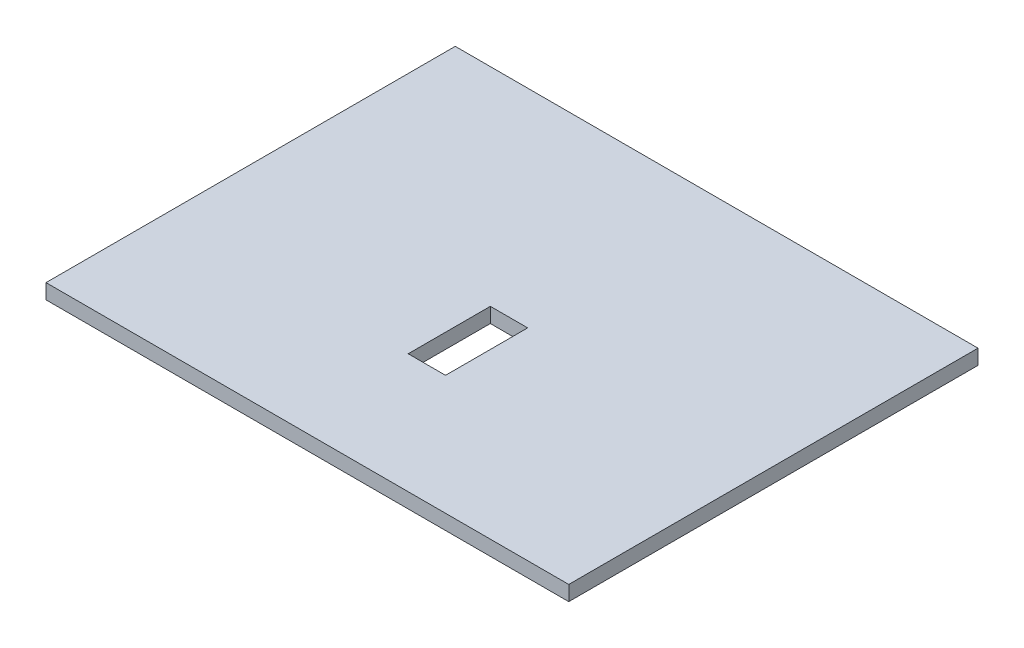
from build123d import *

# Parameters (mm, degrees)
SKETCH1_W           = 350
SKETCH1_H           = 350
BOSS_EXTRUDE1_DEPTH = 10
SKETCH3_W           = 350
SKETCH3_H           = 76
CUT_EXTRUDE1_DEPTH  = 10
SKETCH4_W           = 25
SKETCH4_H           = 55
CUT_EXTRUDE2_DEPTH  = 10


with BuildPart() as part:
    # Sketch1 → Boss-Extrude1 (new body)
    with BuildSketch(Plane(origin=(0, 0, 0), x_dir=(1, 0, 0), z_dir=(0, 1, 0))):
        Rectangle(SKETCH1_W, SKETCH1_H)
    extrude(amount=BOSS_EXTRUDE1_DEPTH)

    # Sketch3 → Cut-Extrude1 (cut)
    with BuildSketch(Plane(origin=(0, 10, 0), x_dir=(1, 0, 0), z_dir=(0, 1, 0))):
        with Locations((0, -137)):
            Rectangle(SKETCH3_W, SKETCH3_H)
    extrude(amount=-CUT_EXTRUDE1_DEPTH, mode=Mode.SUBTRACT)

    # Sketch4 → Cut-Extrude2 (cut)
    with BuildSketch(Plane(origin=(0, 10, 0), x_dir=(1, 0, 0), z_dir=(0, 1, 0))):
        with Locations((0, 8.5)):
            Rectangle(SKETCH4_W, SKETCH4_H)
    extrude(amount=-CUT_EXTRUDE2_DEPTH, mode=Mode.SUBTRACT)


solid = part.part
